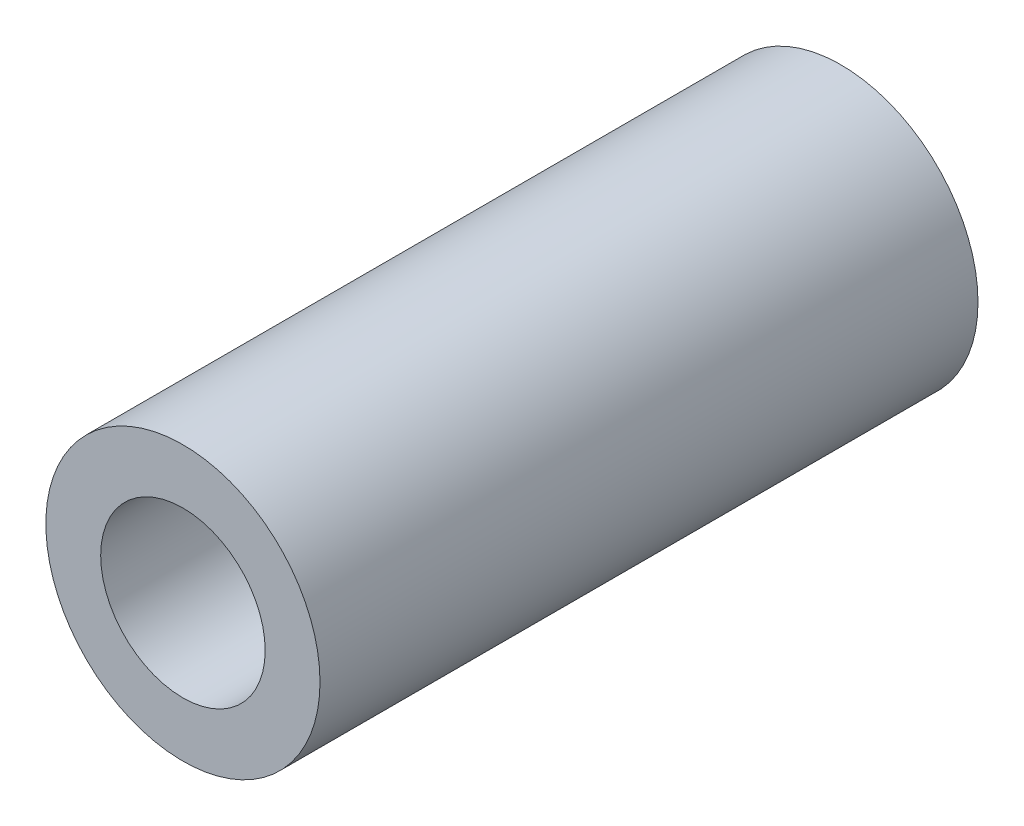
from build123d import *

# Parameters (mm, degrees)
SKETCH_1_R      = 2.5
SKETCH_1_R_2    = 1.5
EXTRUDE_1_DEPTH = 12


with BuildPart() as part:
    # 草图1 → 凸台-拉伸1 (new body)
    with BuildSketch(Plane.XY):
        Circle(SKETCH_1_R)
        Circle(SKETCH_1_R_2, mode=Mode.SUBTRACT)
    extrude(amount=EXTRUDE_1_DEPTH)


solid = part.part
